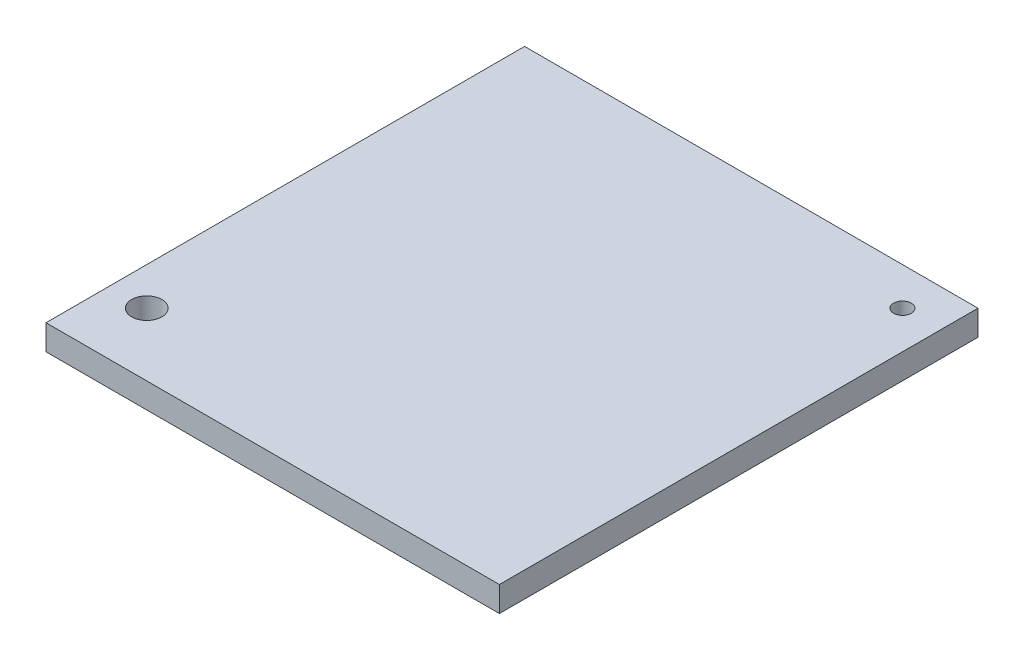
from build123d import *

# Parameters (mm, degrees)
SKETCH1_W           = 180
SKETCH1_H           = 190
BOSS_EXTRUDE1_DEPTH = 10
SKETCH2_R           = 3.5
CUT_EXTRUDE1_DEPTH  = 11
SKETCH6_R           = 6
CUT_EXTRUDE2_DEPTH  = 11


with BuildPart() as part:
    # Sketch1 → Boss-Extrude1 (new body)
    with BuildSketch(Plane(origin=(0, 0, 0), x_dir=(1, 0, 0), z_dir=(0, 1, 0))):
        with Locations((0, -5)):
            Rectangle(SKETCH1_W, SKETCH1_H)
    extrude(amount=BOSS_EXTRUDE1_DEPTH)

    # Sketch2 → Cut-Extrude1 (cut, through all)
    with BuildSketch(Plane(origin=(0, 10, 0), x_dir=(1, 0, 0), z_dir=(0, 1, 0))):
        with Locations((75, 75)):
            Circle(SKETCH2_R)
    extrude(amount=-CUT_EXTRUDE1_DEPTH, mode=Mode.SUBTRACT)

    # Sketch6 → Cut-Extrude2 (cut, through all)
    with BuildSketch(Plane(origin=(0, 10, 0), x_dir=(1, 0, 0), z_dir=(0, 1, 0))):
        with Locations((-75, -75)):
            Circle(SKETCH6_R)
    extrude(amount=-CUT_EXTRUDE2_DEPTH, mode=Mode.SUBTRACT)


solid = part.part
